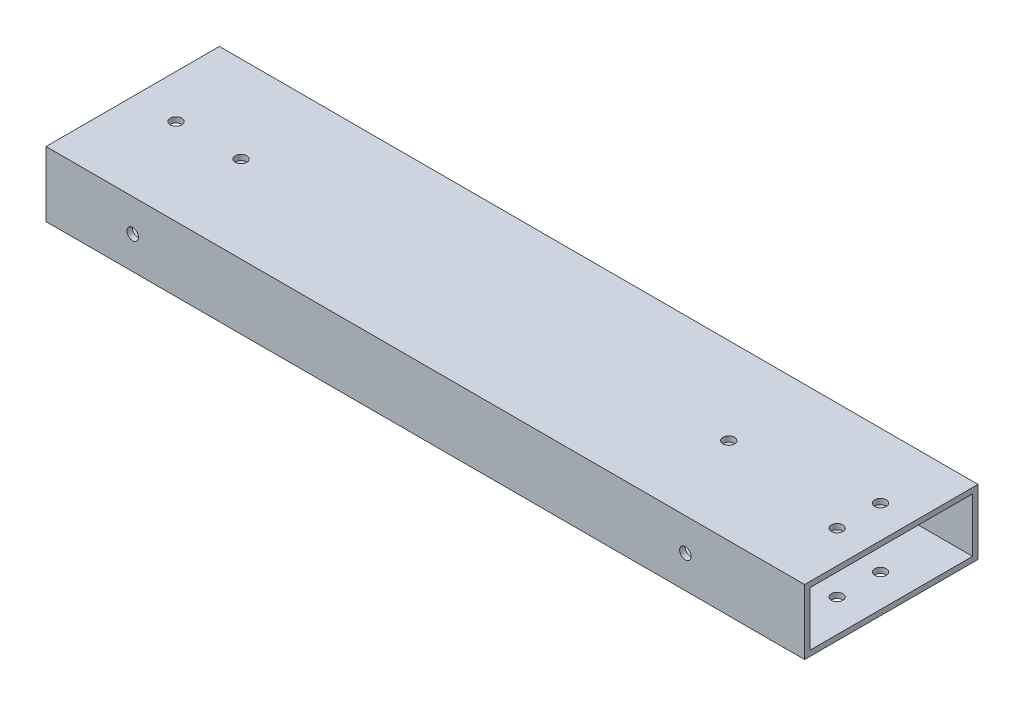
from build123d import *

# Parameters (mm, degrees)
SKETCH1_W                = 101.6
SKETCH1_H                = 38.1
SKETCH1_W_2              = 95.25
SKETCH1_H_2              = 31.75
BOSS_EXTRUDE1_DEPTH      = 444.5
H_0_266_DIAMETER_HOLE1_D = 6.7564
H_0_266_DIAMETER_HOLE2_D = 6.7564


with BuildPart() as part:
    # Sketch1 → Boss-Extrude1 (new body)
    with BuildSketch(Plane(origin=(0, 0, 0), x_dir=(0, 0, -1), z_dir=(1, 0, 0))):
        Rectangle(SKETCH1_W, SKETCH1_H)
        Rectangle(SKETCH1_W_2, SKETCH1_H_2, mode=Mode.SUBTRACT)
    extrude(amount=BOSS_EXTRUDE1_DEPTH)

    # H (0.266) Diameter Hole1 (through all)
    with Locations(Plane(origin=(0, 19.05, 0), x_dir=(1, 0, 0), z_dir=(0, 1, 0))):
        with Locations((25.4, 0), (63.5, 0), (349.25, 0), (425.45, 12.7), (425.45, -12.7)):
            Hole(H_0_266_DIAMETER_HOLE1_D / 2)

    # H (0.266) Diameter Hole2 (through all)
    with Locations(Plane(origin=(0, 0, -50.8), x_dir=(-1, 0, 0), z_dir=(0, 0, -1))):
        with Locations((-50.8, 0), (-374.65, 0)):
            Hole(H_0_266_DIAMETER_HOLE2_D / 2)


solid = part.part
